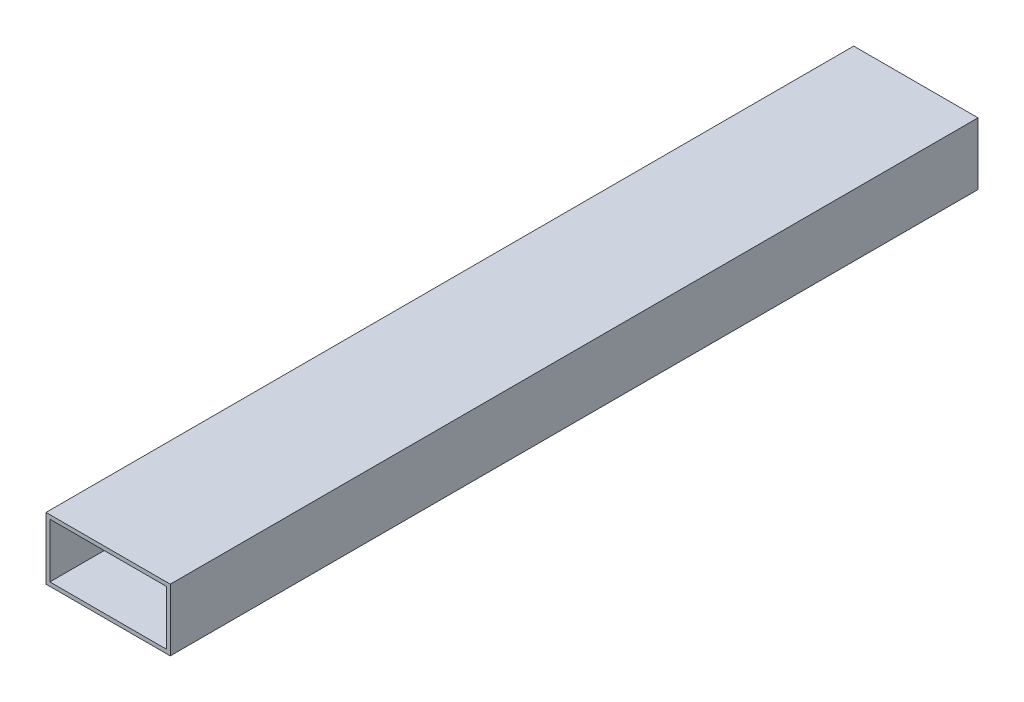
from build123d import *

# Parameters (mm, degrees)
SKETCH1_W           = 50.8
SKETCH1_H           = 25.4
SKETCH1_W_2         = 47.625
SKETCH1_H_2         = 22.225
BOSS_EXTRUDE1_DEPTH = 330.2


with BuildPart() as part:
    # Sketch1 → Boss-Extrude1 (new body)
    with BuildSketch(Plane.XY):
        with Locations((25.4, 12.7)):
            Rectangle(SKETCH1_W, SKETCH1_H)
        with Locations((25.4, 12.7)):
            Rectangle(SKETCH1_W_2, SKETCH1_H_2, mode=Mode.SUBTRACT)
    extrude(amount=BOSS_EXTRUDE1_DEPTH)


solid = part.part
